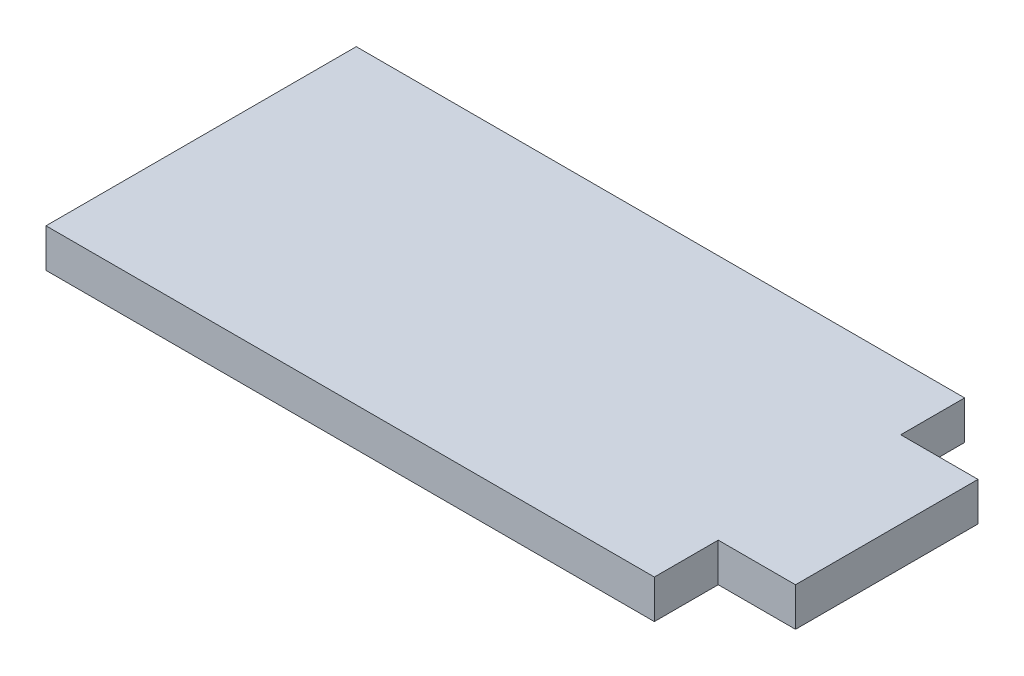
from build123d import *

# Parameters (mm, degrees)
BOSS_EXTRUDE1_DEPTH = 3.175


with BuildPart() as part:
    # Sketch1 → Boss-Extrude1 (new body)
    with BuildSketch(Plane(origin=(0, 0, 0), x_dir=(1, 0, 0), z_dir=(0, 1, 0))):
        Polygon((-25, 0), (-25, 5.25), (25, 5.25), (25, 0), (31.35, 0), (31.35, -15), (25, -15), (25, -20.25), (-25, -20.25), (-25, -15), align=None)
    extrude(amount=BOSS_EXTRUDE1_DEPTH)


solid = part.part
